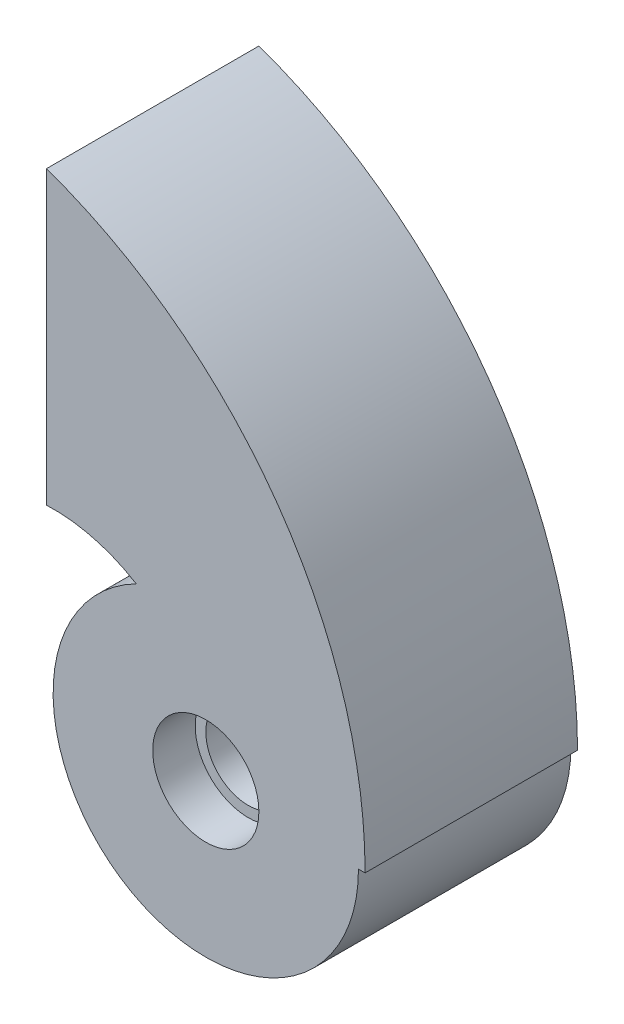
from build123d import *

# Parameters (mm, degrees)
SKETCH_1_R           = 14.375
EXTRUDE_1_DEPTH      = 10
EXTRUDE_1_DEPTH_BACK = 10
EXTRUDE_2_DEPTH      = 20
SKETCH_10_R          = 4
CUT_EXTRUDE_1_DEPTH  = 21
SKETCH_11_R          = 5
CUT_EXTRUDE_2_DEPTH  = 4
SKETCH_12_R          = 5
CUT_EXTRUDE_3_DEPTH  = 4


with BuildPart() as part:
    # Sketch 1 → Extrude 1 (new body, two sides)
    with BuildSketch(Plane.XY) as extrude_1_sk:
        Circle(SKETCH_1_R)
    extrude(amount=EXTRUDE_1_DEPTH)
    extrude(extrude_1_sk.sketch, amount=-EXTRUDE_1_DEPTH_BACK)

    # Sketch 2 → Extrude 2 (add)
    with BuildSketch(Plane.XY.offset(10)):
        with BuildLine():
            Line((-15, 42.426406871), (-15, 14.98697351))
            ThreePointArc((-15, 14.98697351), (-3.991720171, 10.825317547), (0.625, 0))
            Line((0.625, 0), (15, 0))
            ThreePointArc((15, 0), (6.742346142, 25.980762114), (-15, 42.426406871))
        make_face()
    extrude(amount=-EXTRUDE_2_DEPTH)

    # Sketch 10 → Cut-Extrude 1 (cut, through all)
    with BuildSketch(Plane.XY.offset(10)):
        Circle(SKETCH_10_R)
    extrude(amount=-CUT_EXTRUDE_1_DEPTH, mode=Mode.SUBTRACT)

    # Sketch 11 → Cut-Extrude 2 (cut)
    with BuildSketch(Plane(origin=(0, 0, -10), x_dir=(-1, 0, 0), z_dir=(0, 0, -1))):
        Circle(SKETCH_11_R)
    extrude(amount=-CUT_EXTRUDE_2_DEPTH, mode=Mode.SUBTRACT)

    # Sketch 12 → Cut-Extrude 3 (cut)
    with BuildSketch(Plane.XY.offset(10)):
        Circle(SKETCH_12_R)
    extrude(amount=-CUT_EXTRUDE_3_DEPTH, mode=Mode.SUBTRACT)


solid = part.part
